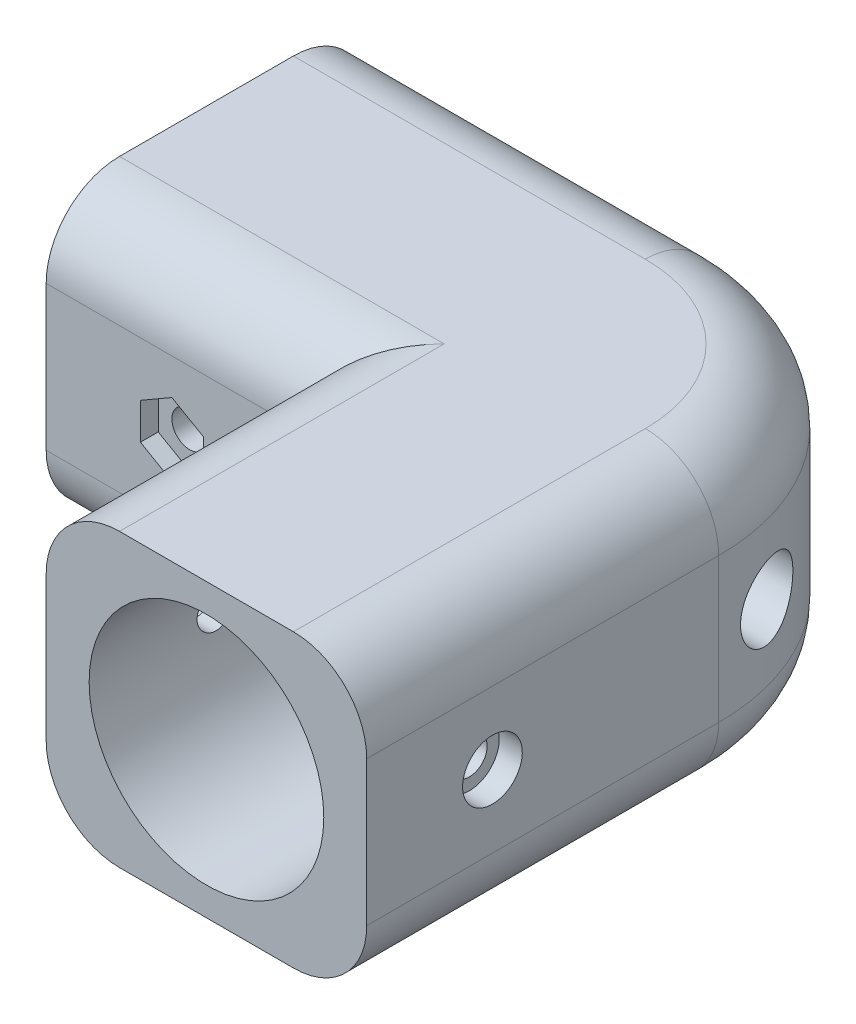
from build123d import *

# Parameters (mm, degrees)
SKETCH1_R           = 13.9
SKETCH1_R_2         = 11.2
BOSS_EXTRUDE1_DEPTH = 7
SKETCH2_W           = 30.6
SKETCH2_H           = 27.8
SKETCH2_R           = 11.2
BOSS_EXTRUDE2_DEPTH = 24
SKETCH6_W           = 30.6
SKETCH6_H           = 27.8
SKETCH6_R           = 11.2
BOSS_EXTRUDE6_DEPTH = 24
SKETCH7_W           = 30.6
SKETCH7_H           = 30.6
BOSS_EXTRUDE7_DEPTH = 27.8
FILLET1_R           = 21
FILLET2_R           = 7
SKETCH8_R           = 3.5
CUT_EXTRUDE1_DEPTH  = 31.6000001
SKETCH9_R           = 3.5
CUT_EXTRUDE2_DEPTH  = 31.6000001
CUT_EXTRUDE3_DEPTH  = 2.2
SKETCH12_R          = 1.7
CUT_EXTRUDE4_DEPTH  = 29.4000001
SKETCH13_R          = 2.85
CUT_EXTRUDE5_DEPTH  = 2.2
CUT_EXTRUDE6_DEPTH  = 1.7
SKETCH16_R          = 1.7
CUT_EXTRUDE7_DEPTH  = 29.9000001
SKETCH17_R          = 2.85
CUT_EXTRUDE8_DEPTH  = 1.7


with BuildPart() as part:
    # Sketch1 → Boss-Extrude1 (new body)
    with BuildSketch(Plane.XY):
        Circle(SKETCH1_R)
        Circle(SKETCH1_R_2, mode=Mode.SUBTRACT)
    extrude(amount=BOSS_EXTRUDE1_DEPTH)

    # Sketch2 → Boss-Extrude2 (add)
    with BuildSketch(Plane.XY.offset(7)):
        Rectangle(SKETCH2_W, SKETCH2_H)
        Circle(SKETCH2_R, mode=Mode.SUBTRACT)
    extrude(amount=-BOSS_EXTRUDE2_DEPTH)



with BuildPart() as body_2:
    # Sketch6 → Boss-Extrude6 (new body)
    with BuildSketch(Plane.ZY.offset(15.3)):
        with Locations((-32.3, 0)):
            Rectangle(SKETCH6_W, SKETCH6_H)
        with Locations((-32.3, 0)):
            Circle(SKETCH6_R, mode=Mode.SUBTRACT)
    extrude(amount=BOSS_EXTRUDE6_DEPTH)


with BuildPart() as part_1:
    add(part.part)

    add(body_2.part)  # Boss-Extrude7 merges body 2
    # Sketch7 → Boss-Extrude7 (add)
    with BuildSketch(Plane(origin=(0, 13.9, 0), x_dir=(1, 0, 0), z_dir=(0, 1, 0))):
        with Locations((0, 32.3)):
            Rectangle(SKETCH7_W, SKETCH7_H)
    extrude(amount=-BOSS_EXTRUDE7_DEPTH)

    # Fillet1
    fillet1_edges = [part_1.edges().sort_by_distance(p)[0] for p in [
        (15.3, 0, -47.6),
    ]]
    fillet(fillet1_edges, radius=FILLET1_R)

    # Fillet2
    fillet2_edges = [part_1.edges().sort_by_distance(p)[0] for p in [
        (-22.5, -13.9, -47.6),
        (-15.3, 13.9, -5),
        (-15.3, -13.9, -5),
        (-27.3, 13.9, -17),
        (-27.3, -13.9, -17),
        (15.3, -13.9, -9.8),
        (15.3, 13.9, -9.8),
        (-22.5, 13.9, -47.6),
        (9.149242405, 13.9, -41.449242405),
        (9.149242405, -13.9, -41.449242405),
    ]]
    fillet(fillet2_edges, radius=FILLET2_R)

    # Sketch8 → Cut-Extrude1 (cut, through all)
    with BuildSketch(Plane.ZY.offset(15.3)):
        with Locations((-32.3, 0)):
            Circle(SKETCH8_R)
    extrude(amount=-CUT_EXTRUDE1_DEPTH, mode=Mode.SUBTRACT)

    # Sketch9 → Cut-Extrude2 (cut, through all)
    with BuildSketch(Plane.XY.offset(-17)):
        Circle(SKETCH9_R)
    extrude(amount=-CUT_EXTRUDE2_DEPTH, mode=Mode.SUBTRACT)

    # Sketch11 → Cut-Extrude3 (cut)
    with BuildSketch(Plane.ZY.offset(15.3)):
        Polygon((-2, -1.732050808), (-2, 1.732050808), (-5, 3.464101615), (-8, 1.732050808), (-8, -1.732050808), (-5, -3.464101615), align=None)
    extrude(amount=-CUT_EXTRUDE3_DEPTH, mode=Mode.SUBTRACT)

    # Sketch12 → Cut-Extrude4 (cut, through all)
    with BuildSketch(Plane.ZY.offset(13.1)):
        with Locations((-5, 0)):
            Circle(SKETCH12_R)
    extrude(amount=-CUT_EXTRUDE4_DEPTH, mode=Mode.SUBTRACT)

    # Sketch13 → Cut-Extrude5 (cut)
    with BuildSketch(Plane(origin=(15.3, 0, 0), x_dir=(0, 0, -1), z_dir=(1, 0, 0))):
        with Locations((5, 0)):
            Circle(SKETCH13_R)
    extrude(amount=-CUT_EXTRUDE5_DEPTH, mode=Mode.SUBTRACT)

    # Sketch15 → Cut-Extrude6 (cut)
    with BuildSketch(Plane.XY.offset(-17)):
        Polygon((-24.3, -1.732050808), (-24.3, 1.732050808), (-27.3, 3.464101615), (-30.3, 1.732050808), (-30.3, -1.732050808), (-27.3, -3.464101615), align=None)
    extrude(amount=-CUT_EXTRUDE6_DEPTH, mode=Mode.SUBTRACT)

    # Sketch16 → Cut-Extrude7 (cut, through all)
    with BuildSketch(Plane.XY.offset(-18.7)):
        with Locations((-27.3, 0)):
            Circle(SKETCH16_R)
    extrude(amount=-CUT_EXTRUDE7_DEPTH, mode=Mode.SUBTRACT)

    # Sketch17 → Cut-Extrude8 (cut)
    with BuildSketch(Plane(origin=(0, 0, -47.6), x_dir=(-1, 0, 0), z_dir=(0, 0, -1))):
        with Locations((27.3, 0)):
            Circle(SKETCH17_R)
    extrude(amount=-CUT_EXTRUDE8_DEPTH, mode=Mode.SUBTRACT)


solid = part_1.part
